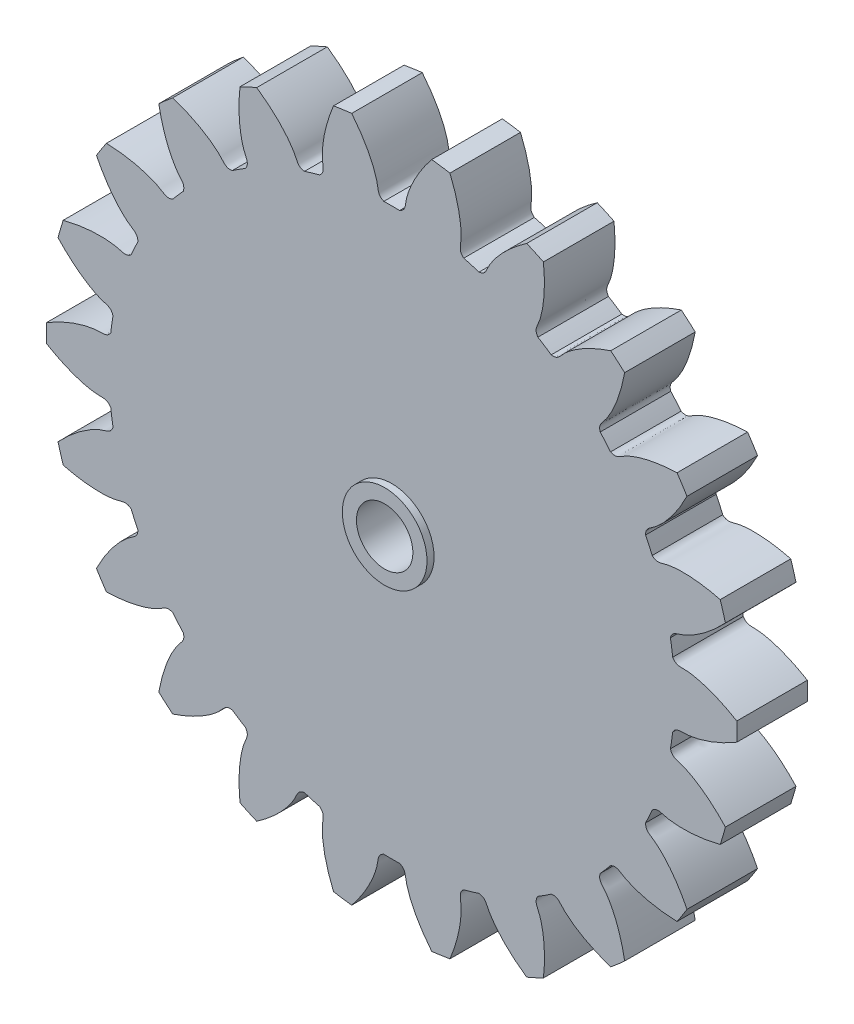
from build123d import *

# Parameters (mm, degrees)
SKETCH_1_R               = 24.4602
EXTRUDE_1_DEPTH          = 5
CUT_EXTRUDE_1_DEPTH      = 35.951434421
PATTERN_CIRCULAR_1_COUNT = 22
SKETCH_4_R               = 3
EXTRUDE_2_DEPTH          = 0.5
SKETCH_5_R               = 2
CUT_EXTRUDE_2_DEPTH      = 35.911580332
CHAMFER_1_SIZE           = 0.5


with BuildPart() as part:
    # 草图1 → 凸台-拉伸1 (new body)
    with BuildSketch(Plane.XY):
        Circle(SKETCH_1_R)
    extrude(amount=EXTRUDE_1_DEPTH)

    # 草图2 → 切除-拉伸1 (cut, through all)
    with BuildSketch(Plane.XY):
        with BuildLine():
            ThreePointArc((0.562620012, 20.032100707), (0, 20.04), (-0.562620012, 20.032100707))
            add(Edge.make_bspline(
                [(-0.562620012, 20.032100707), (-0.96395803, 20.204302235), (-0.953973835, 20.524272483), (-1.013453551, 20.852994988), (-1.025662524, 20.913804487), (-1.040884578, 20.982429006), (-1.059418467, 21.058773705), (-1.081584032, 21.142728889), (-1.107690428, 21.234177101), (-1.13804587, 21.332990978), (-1.172954263, 21.439034028), (-1.212715913, 21.552160515), (-1.257626988, 21.672215622), (-1.307979364, 21.799035533), (-1.364060356, 21.93244756), (-1.426152491, 22.072270248), (-1.494533267, 22.218313508), (-1.569474924, 22.370378742), (-1.651244214, 22.528258981), (-1.740102177, 22.691739025), (-1.836303918, 22.860595589), (-1.940098387, 23.034597456), (-2.051728169, 23.213505638), (-2.171429269, 23.397073534), (-2.299430906, 23.585047104), (-2.435955314, 23.777165038), (-2.581217539, 23.973158939), (-2.735425249, 24.172753503), (-2.898778541, 24.375666714), (-3.071469759, 24.581610029), (-3.253683314, 24.790288585), (-3.445595506, 25.001401396), (-3.647374358, 25.214641563), (-3.859179448, 25.429696485), (-4.081161748, 25.646248077), (-4.313463474, 25.863972986), (-4.556217932, 26.082542817), (-4.809549376, 26.301624363), (-5.07357287, 26.520879834), (-5.348394154, 26.739967091), (-5.634109529, 26.95853989), (-5.930805672, 27.17624812), (-6.345653721, 27.468073356), (-6.66678383, 27.679717933), (-6.885875614, 27.818041259)],
                knots=[0, 0, 0, 0, 0.086360646, 0.091597556, 0.097640144, 0.104488411, 0.112142356, 0.12060198, 0.129867282, 0.139938263, 0.150814922, 0.162497259, 0.174985275, 0.18827897, 0.202378342, 0.217283394, 0.232994123, 0.249510531, 0.266832618, 0.284960383, 0.303893826, 0.323632948, 0.344177748, 0.365528227, 0.387684384, 0.41064622, 0.434413734, 0.458986926, 0.484365797, 0.510550347, 0.537540575, 0.565336481, 0.593938065, 0.623345329, 0.65355827, 0.68457689, 0.716401189, 0.749031165, 0.782466821, 0.816708155, 0.851755167, 0.887607857, 0.924266227, 1, 1, 1, 1], degree=3))
            ThreePointArc((-6.885875614, 27.818041259), (0, 28.657611597), (6.885875614, 27.818041259))
            add(Edge.make_bspline(
                [(0.562620012, 20.032100707), (0.96395803, 20.204302235), (0.953973835, 20.524272483), (1.013453551, 20.852994988), (1.025662524, 20.913804487), (1.040884578, 20.982429006), (1.059418467, 21.058773705), (1.081584032, 21.142728889), (1.107690428, 21.234177101), (1.13804587, 21.332990978), (1.172954263, 21.439034028), (1.212715913, 21.552160515), (1.257626988, 21.672215622), (1.307979364, 21.799035533), (1.364060356, 21.93244756), (1.426152491, 22.072270248), (1.494533267, 22.218313508), (1.569474924, 22.370378742), (1.651244214, 22.528258981), (1.740102177, 22.691739025), (1.836303918, 22.860595589), (1.940098387, 23.034597456), (2.051728169, 23.213505638), (2.171429269, 23.397073534), (2.299430906, 23.585047104), (2.435955314, 23.777165038), (2.581217539, 23.973158939), (2.735425249, 24.172753503), (2.898778541, 24.375666714), (3.071469759, 24.581610029), (3.253683314, 24.790288585), (3.445595506, 25.001401396), (3.647374358, 25.214641563), (3.859179448, 25.429696485), (4.081161748, 25.646248077), (4.313463474, 25.863972986), (4.556217932, 26.082542817), (4.809549376, 26.301624363), (5.07357287, 26.520879834), (5.348394154, 26.739967091), (5.634109529, 26.95853989), (5.930805672, 27.17624812), (6.345653721, 27.468073356), (6.66678383, 27.679717933), (6.885875614, 27.818041259)],
                knots=[0, 0, 0, 0, 0.086360646, 0.091597556, 0.097640144, 0.104488411, 0.112142356, 0.12060198, 0.129867282, 0.139938263, 0.150814922, 0.162497259, 0.174985275, 0.18827897, 0.202378342, 0.217283394, 0.232994123, 0.249510531, 0.266832618, 0.284960383, 0.303893826, 0.323632948, 0.344177748, 0.365528227, 0.387684384, 0.41064622, 0.434413734, 0.458986926, 0.484365797, 0.510550347, 0.537540575, 0.565336481, 0.593938065, 0.623345329, 0.65355827, 0.68457689, 0.716401189, 0.749031165, 0.782466821, 0.816708155, 0.851755167, 0.887607857, 0.924266227, 1, 1, 1, 1], degree=3))
        make_face()
    cut_extrude_1 = extrude(amount=CUT_EXTRUDE_1_DEPTH, mode=Mode.SUBTRACT)

    # 阵列(圆周)1: 切除-拉伸1 ×22 about axis
    pattern_circular_1_axis = Axis((0, 0, -0.25), (0, 0, 1))
    for i in range(1, PATTERN_CIRCULAR_1_COUNT):
        add(cut_extrude_1.rotate(pattern_circular_1_axis, i * 360 / PATTERN_CIRCULAR_1_COUNT), mode=Mode.SUBTRACT)

    # 草图4 → 凸台-拉伸2 (add)
    with BuildSketch(Plane.XY.offset(5)):
        Circle(SKETCH_4_R)
    extrude(amount=EXTRUDE_2_DEPTH)

    # 草图5 → 切除-拉伸2 (cut, through all)
    with BuildSketch(Plane.XY.offset(5.5)):
        Circle(SKETCH_5_R)
    extrude(amount=-CUT_EXTRUDE_2_DEPTH, mode=Mode.SUBTRACT)

    # 倒角1
    chamfer_1_edges = [part.edges().sort_by_distance(p)[0] for p in [
        (-2, 0, 0),
    ]]
    chamfer(chamfer_1_edges, length=CHAMFER_1_SIZE)


solid = part.part
